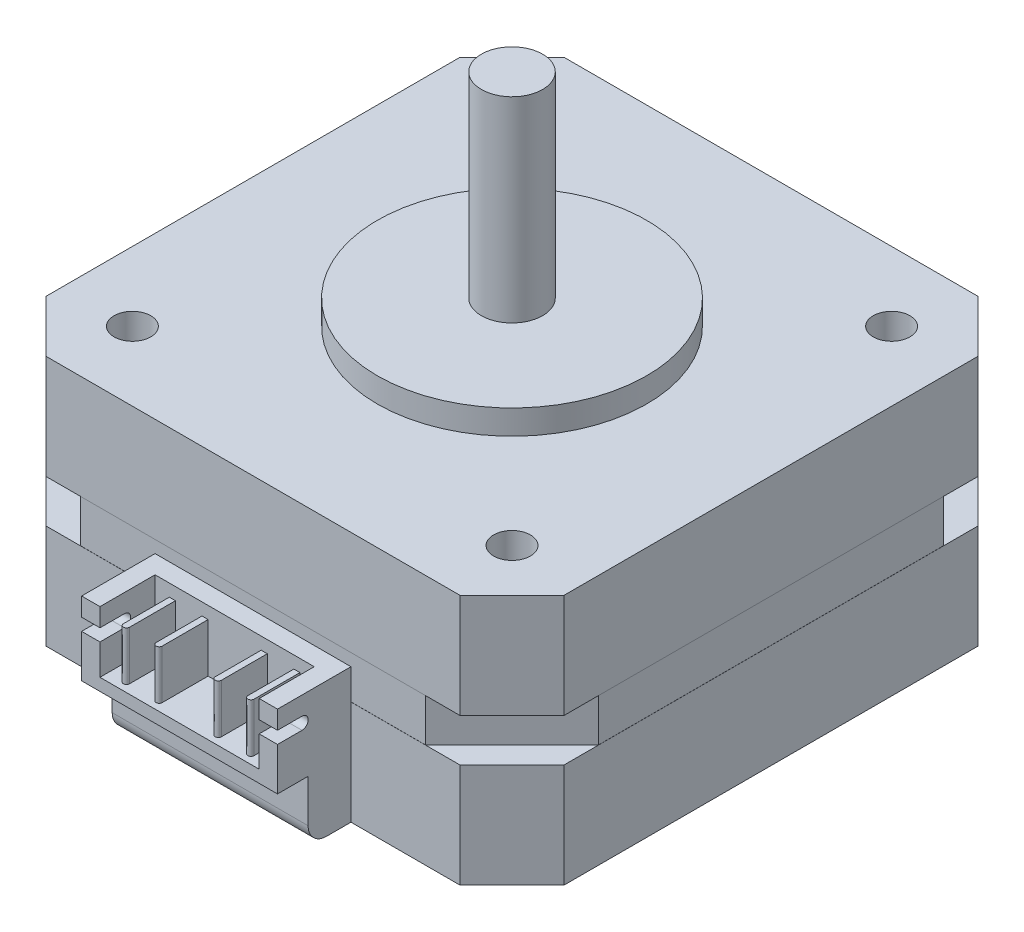
from build123d import *

# Parameters (mm, degrees)
SKETCH1_W               = 42.3
SKETCH1_H               = 42.3
BOSS_EXTRUDE1_DEPTH     = 20.5
SKETCH2_R               = 11
BOSS_EXTRUDE2_DEPTH     = 2
SKETCH3_R               = 2.5
BOSS_EXTRUDE3_DEPTH     = 16
CUT_EXTRUDE1_DEPTH      = 19
CUT_EXTRUDE1_DEPTH_BACK = 21.5
SKETCH5_W               = 33.814718626
SKETCH5_H               = 3.5
CUT_EXTRUDE2_DEPTH      = 0.01
CUT_EXTRUDE3_START      = -12
CUT_EXTRUDE3_DEPTH      = 3.5
CIRPATTERN1_COUNT       = 4
SKETCH7_R               = 1.5
CUT_EXTRUDE4_DEPTH      = 4.5
SKETCH8_W               = 16
SKETCH8_H               = 11
BOSS_EXTRUDE4_DEPTH     = 6
SKETCH9_W               = 16
SKETCH9_H               = 5
CUT_EXTRUDE5_DEPTH      = 2.5
FILLET1_R               = 1.5
SKETCH10_W              = 13
SKETCH10_H              = 4.5
CUT_EXTRUDE6_DEPTH      = 5
CUT_EXTRUDE7_DEPTH      = 30.15
BOSS_EXTRUDE5_DEPTH     = 4


with BuildPart() as part:
    # Sketch1 → Boss-Extrude1 (new body)
    with BuildSketch(Plane(origin=(0, 0, 0), x_dir=(1, 0, 0), z_dir=(0, 1, 0))):
        Rectangle(SKETCH1_W, SKETCH1_H)
    extrude(amount=BOSS_EXTRUDE1_DEPTH)

    # Sketch2 → Boss-Extrude2 (add)
    with BuildSketch(Plane(origin=(0, 20.5, 0), x_dir=(1, 0, 0), z_dir=(0, 1, 0))):
        Circle(SKETCH2_R)
    extrude(amount=BOSS_EXTRUDE2_DEPTH)

    # Sketch3 → Boss-Extrude3 (add)
    with BuildSketch(Plane(origin=(0, 22.5, 0), x_dir=(1, 0, 0), z_dir=(0, 1, 0))):
        Circle(SKETCH3_R)
    extrude(amount=BOSS_EXTRUDE3_DEPTH)

    # Sketch4 → Cut-Extrude1 (cut, two sides)
    with BuildSketch(Plane(origin=(0, 20.5, 0), x_dir=(1, 0, 0), z_dir=(0, 1, 0))) as cut_extrude1_sk:
        Polygon((-21.15, 16.907359313), (-16.907359313, 21.15), (-21.15, 21.15), align=None)
        Polygon((21.15, 21.15), (21.15, 16.907359313), (16.907359313, 21.15), align=None)
        Polygon((21.15, -16.907359313), (16.907359313, -21.15), (21.15, -21.15), align=None)
        Polygon((-21.15, -21.15), (-21.15, -16.907359313), (-16.907359313, -21.15), align=None)
    extrude(amount=CUT_EXTRUDE1_DEPTH, mode=Mode.SUBTRACT)
    extrude(cut_extrude1_sk.sketch, amount=-CUT_EXTRUDE1_DEPTH_BACK, mode=Mode.SUBTRACT)

    # Sketch5 → Cut-Extrude2 (cut)
    with BuildSketch(Plane(origin=(21.15, 0, 0), x_dir=(0, 0, -1), z_dir=(1, 0, 0))):
        with Locations((0, 10.25)):
            Rectangle(SKETCH5_W, SKETCH5_H)
    cut_extrude2 = extrude(amount=-CUT_EXTRUDE2_DEPTH, mode=Mode.SUBTRACT)

    # Sketch6 → Cut-Extrude3 (cut)
    with BuildSketch(Plane(origin=(0, 20.5, 0), x_dir=(1, 0, 0), z_dir=(0, 1, 0)).offset(CUT_EXTRUDE3_START)):
        Polygon((21.15, 14.078932188), (14.078932188, 21.15), (21.15, 21.15), align=None)
    cut_extrude3 = extrude(amount=CUT_EXTRUDE3_DEPTH, mode=Mode.SUBTRACT)

    # CirPattern1: Cut-Extrude2, Cut-Extrude3 ×4 about axis
    cirpattern1_axis = Axis((0, 0, 0), (0, 1, 0))
    for i in range(1, CIRPATTERN1_COUNT):
        add(cut_extrude2.rotate(cirpattern1_axis, i * 360 / CIRPATTERN1_COUNT), mode=Mode.SUBTRACT)
        add(cut_extrude3.rotate(cirpattern1_axis, i * 360 / CIRPATTERN1_COUNT), mode=Mode.SUBTRACT)

    # Sketch7 → Cut-Extrude4 (cut)
    with BuildSketch(Plane(origin=(0, 20.5, 0), x_dir=(1, 0, 0), z_dir=(0, 1, 0))):
        with Locations((15.5, 15.5)):
            Circle(SKETCH7_R)
        with Locations((15.5, -15.5)):
            Circle(SKETCH7_R)
        with Locations((-15.5, -15.5)):
            Circle(SKETCH7_R)
        with Locations((-15.5, 15.5)):
            Circle(SKETCH7_R)
    extrude(amount=-CUT_EXTRUDE4_DEPTH, mode=Mode.SUBTRACT)

    # Sketch8 → Boss-Extrude4 (add)
    with BuildSketch(Plane.XY.offset(21.15)):
        with Locations((0, 5.5)):
            Rectangle(SKETCH8_W, SKETCH8_H)
    extrude(amount=BOSS_EXTRUDE4_DEPTH)

    # Sketch9 → Cut-Extrude5 (cut)
    with BuildSketch(Plane.XY.offset(27.15)):
        with Locations((0, 2.5)):
            Rectangle(SKETCH9_W, SKETCH9_H)
    extrude(amount=-CUT_EXTRUDE5_DEPTH, mode=Mode.SUBTRACT)

    # Fillet1
    fillet1_edges = [part.edges().sort_by_distance(p)[0] for p in [
        (0, 0, 24.65),
    ]]
    fillet(fillet1_edges, radius=FILLET1_R)

    # Sketch10 → Cut-Extrude6 (cut)
    with BuildSketch(Plane(origin=(0, 11, 0), x_dir=(1, 0, 0), z_dir=(0, 1, 0))):
        with Locations((0, -24.9)):
            Rectangle(SKETCH10_W, SKETCH10_H)
    extrude(amount=-CUT_EXTRUDE6_DEPTH, mode=Mode.SUBTRACT)

    # Sketch11 → Cut-Extrude7 (cut, through all)
    with BuildSketch(Plane(origin=(8, 0, 0), x_dir=(0, 0, -1), z_dir=(1, 0, 0))):
        with BuildLine():
            Line((-27.15, 9.5), (-25.15, 9.5))
            ThreePointArc((-25.15, 9.5), (-24.65, 9), (-25.15, 8.5))
            Line((-25.15, 8.5), (-27.15, 8.5))
            Line((-27.15, 8.5), (-27.15, 9.5))
        make_face()
    extrude(amount=-CUT_EXTRUDE7_DEPTH, mode=Mode.SUBTRACT)

    # Sketch12 → Boss-Extrude5 (add)
    with BuildSketch(Plane(origin=(0, 6, 0), x_dir=(1, 0, 0), z_dir=(0, 1, 0))):
        with BuildLine():
            Line((-2.667, -22.65), (-2.167, -22.65))
            Line((-2.167, -22.65), (-2.167, -26.4))
            ThreePointArc((-2.167, -26.4), (-2.417, -26.65), (-2.667, -26.4))
            Line((-2.667, -26.4), (-2.667, -22.65))
        make_face()
        with BuildLine():
            Line((5.334, -22.65), (5.334, -26.4))
            ThreePointArc((5.334, -26.4), (5.084, -26.65), (4.834, -26.4))
            Line((4.834, -26.4), (4.834, -22.65))
            Line((4.834, -22.65), (5.334, -22.65))
        make_face()
        with BuildLine():
            Line((-4.834, -22.65), (-5.334, -22.65))
            Line((-5.334, -22.65), (-5.334, -26.4))
            ThreePointArc((-5.334, -26.4), (-5.084, -26.65), (-4.834, -26.4))
            Line((-4.834, -26.4), (-4.834, -22.65))
        make_face()
        with BuildLine():
            Line((2.167, -22.65), (2.167, -26.4))
            ThreePointArc((2.167, -26.4), (2.417, -26.65), (2.667, -26.4))
            Line((2.667, -26.4), (2.667, -22.65))
            Line((2.667, -22.65), (2.167, -22.65))
        make_face()
    extrude(amount=BOSS_EXTRUDE5_DEPTH)


solid = part.part
